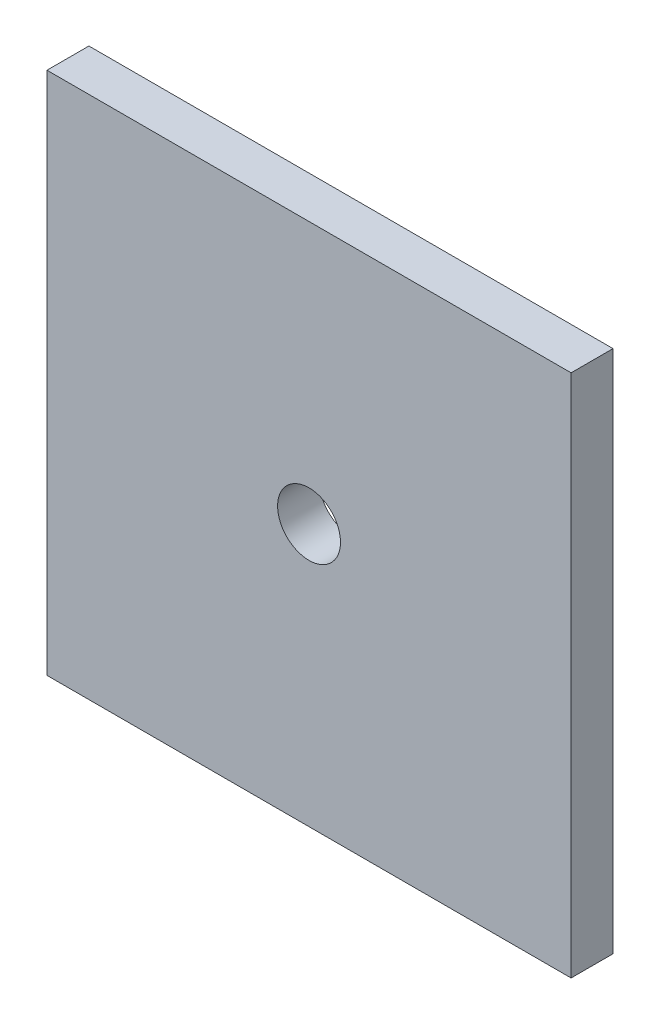
from build123d import *

# Parameters (mm, degrees)
SKETCH1_W           = 50
SKETCH1_H           = 50
BOSS_EXTRUDE1_DEPTH = 4
SKETCH3_R           = 3
CUT_EXTRUDE1_DEPTH  = 4


with BuildPart() as part:
    # Sketch1 → Boss-Extrude1 (new body)
    with BuildSketch(Plane.XY):
        with Locations((25, 25)):
            Rectangle(SKETCH1_W, SKETCH1_H)
    extrude(amount=BOSS_EXTRUDE1_DEPTH)

    # Sketch3 → Cut-Extrude1 (cut)
    with BuildSketch(Plane.XY.offset(4)):
        with Locations((25, 25)):
            Circle(SKETCH3_R)
    extrude(amount=-CUT_EXTRUDE1_DEPTH, mode=Mode.SUBTRACT)


solid = part.part
